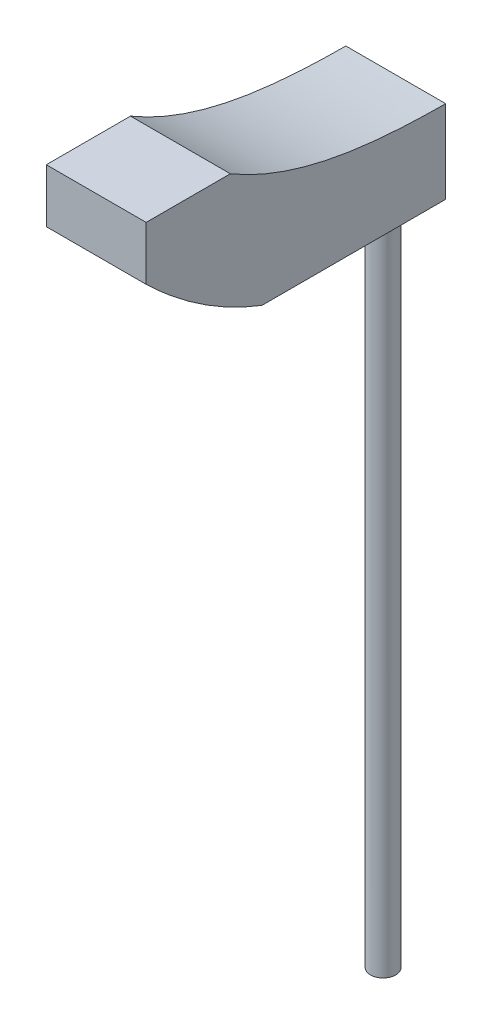
from build123d import *

# Parameters (mm, degrees)
SKETCH1_R           = 12.7
BOSS_EXTRUDE1_DEPTH = 815
BOSS_EXTRUDE2_DEPTH = 130
CUT_EXTRUDE1_DEPTH  = 101


with BuildPart() as part:
    # Sketch1 → Boss-Extrude1 (new body)
    with BuildSketch(Plane(origin=(0, 0, 0), x_dir=(1, 0, 0), z_dir=(0, 1, 0))):
        Circle(SKETCH1_R)
    extrude(amount=BOSS_EXTRUDE1_DEPTH)

    # Sketch3 → Boss-Extrude2 (add)
    with BuildSketch(Plane(origin=(0, 815, 0), x_dir=(1, 0, 0), z_dir=(0, 1, 0))):
        Polygon((0, 12.7), (-50, 12.7), (-50, -287.3), (50, -287.3), (50, 12.7), align=None)
    extrude(amount=-BOSS_EXTRUDE2_DEPTH)

    # Sketch5 → Cut-Extrude1 (cut, through all)
    with BuildSketch(Plane(origin=(50, 0, 0), x_dir=(0, 0, -1), z_dir=(1, 0, 0))):
        with BuildLine():
            Line((-202.978744698, 815), (-272.862835617, 879.498966907))
            Line((-272.862835617, 879.498966907), (20.796594256, 879.498966907))
            Line((20.796594256, 879.498966907), (67.402863197, 768.490286219))
            add(Edge.make_bspline(
                [(-202.978744698, 815), (-120.413068906, 766.120158396), (-24.484780787, 766.761518937), (67.402863197, 768.490286219)],
                knots=[0, 0, 0, 0, 1, 1, 1, 1], degree=3))
        make_face()
        with BuildLine():
            Line((-301.698496964, 775.832281678), (-354.195317799, 601.764613469))
            Line((-354.195317799, 601.764613469), (-151.062921175, 574.818479223))
            Line((-151.062921175, 574.818479223), (-63.792664277, 665.742090059))
            add(Edge.make_bspline(
                [(-301.698496964, 775.832281678), (-196.773017202, 664.797399326), (-63.792664277, 665.742090059)],
                knots=[0, 0, 0, 1, 1, 1], degree=2))
        make_face()
    extrude(amount=-CUT_EXTRUDE1_DEPTH, mode=Mode.SUBTRACT)


solid = part.part
